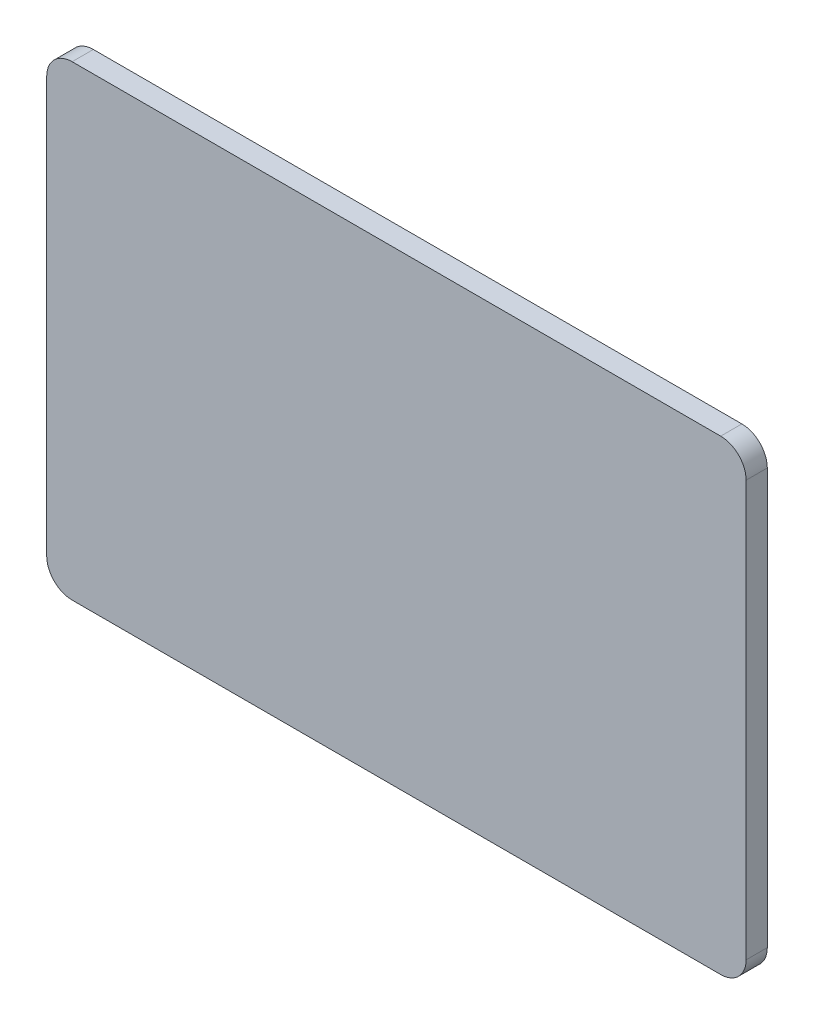
from build123d import *

# Parameters (mm, degrees)
SKETCH1_W           = 825
SKETCH1_H           = 550
BOSS_EXTRUDE1_DEPTH = 25
FILLET1_R           = 30
FILLET2_R           = 30
FILLET3_R           = 30
FILLET4_R           = 30


with BuildPart() as part:
    # Sketch1 → Boss-Extrude1 (new body)
    with BuildSketch(Plane.XY):
        with Locations((412.5, 275)):
            Rectangle(SKETCH1_W, SKETCH1_H)
    extrude(amount=BOSS_EXTRUDE1_DEPTH)

    # Fillet1
    fillet1_edges = [part.edges().sort_by_distance(p)[0] for p in [
        (0, 550, 12.5),
    ]]
    fillet(fillet1_edges, radius=FILLET1_R)

    # Fillet2
    fillet2_edges = [part.edges().sort_by_distance(p)[0] for p in [
        (825, 550, 12.5),
    ]]
    fillet(fillet2_edges, radius=FILLET2_R)

    # Fillet3
    fillet3_edges = [part.edges().sort_by_distance(p)[0] for p in [
        (0, 0, 12.5),
    ]]
    fillet(fillet3_edges, radius=FILLET3_R)

    # Fillet4
    fillet4_edges = [part.edges().sort_by_distance(p)[0] for p in [
        (825, 0, 12.5),
    ]]
    fillet(fillet4_edges, radius=FILLET4_R)


solid = part.part
